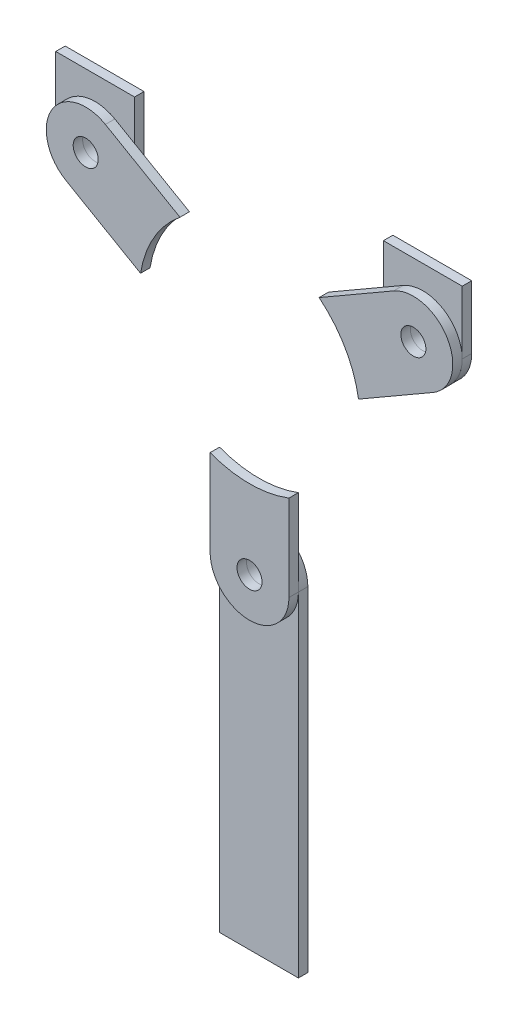
from build123d import *

# Parameters (mm, degrees)
SKETCH1_R             = 3.96875
BOSS_EXTRUDE1_DEPTH   = 3
BOSS_EXTRUDE1_2_DEPTH = 3
BOSS_EXTRUDE1_3_DEPTH = 3
SKETCH2_R             = 3.96875
BOSS_EXTRUDE2_DEPTH   = 3
BOSS_EXTRUDE2_2_DEPTH = 3
BOSS_EXTRUDE2_3_DEPTH = 3


with BuildPart() as part:
    # Sketch1 → Boss-Extrude1 (new body)
    with BuildSketch(Plane.XY):
        with BuildLine():
            ThreePointArc((-45.711524227, 40.825317547), (-62.786841774, 36.25), (-58.211524227, 19.174682453))
            Line((-58.211524227, 19.174682453), (-34.561879132, 5.520553491))
            ThreePointArc((-34.561879132, 5.520553491), (-30.310889132, 17.5), (-22.061879132, 27.171188586))
            Line((-22.061879132, 27.171188586), (-45.711524227, 40.825317547))
        make_face()
        with Locations((-51.961524227, 30)):
            Circle(SKETCH1_R, mode=Mode.SUBTRACT)
    extrude(amount=BOSS_EXTRUDE1_DEPTH)


with BuildPart() as body_2:
    # Sketch1 → Boss-Extrude1 2 (new body)
    with BuildSketch(Plane.XY):
        with BuildLine():
            ThreePointArc((58.211524227, 19.174682453), (62.786841774, 36.25), (45.711524227, 40.825317547))
            Line((45.711524227, 40.825317547), (22.061879132, 27.171188586))
            ThreePointArc((22.061879132, 27.171188586), (30.310889132, 17.5), (34.561879132, 5.520553491))
            Line((34.561879132, 5.520553491), (58.211524227, 19.174682453))
        make_face()
        with Locations((51.961524227, 30)):
            Circle(SKETCH1_R, mode=Mode.SUBTRACT)
    extrude(amount=BOSS_EXTRUDE1_2_DEPTH)


with BuildPart() as body_3:
    # Sketch1 → Boss-Extrude1 3 (new body)
    with BuildSketch(Plane.XY):
        with BuildLine():
            ThreePointArc((-12.5, -60), (0, -72.5), (12.5, -60))
            Line((12.5, -60), (12.5, -32.691742077))
            ThreePointArc((12.5, -32.691742077), (0, -35), (-12.5, -32.691742077))
            Line((-12.5, -32.691742077), (-12.5, -60))
        make_face()
        with Locations((0, -60)):
            Circle(SKETCH1_R, mode=Mode.SUBTRACT)
    extrude(amount=BOSS_EXTRUDE1_3_DEPTH)


with BuildPart() as body_4:
    # Sketch2 → Boss-Extrude2 (new body)
    with BuildSketch(Plane.XY):
        with BuildLine():
            Line((-64.461524227, 30), (-64.461524227, 50))
            Line((-64.461524227, 50), (-39.461524227, 50))
            Line((-39.461524227, 50), (-39.461524227, 30))
            ThreePointArc((-39.461524227, 30), (-51.961524227, 17.5), (-64.461524227, 30))
        make_face()
        with Locations((-51.961524227, 30)):
            Circle(SKETCH2_R, mode=Mode.SUBTRACT)
    extrude(amount=-BOSS_EXTRUDE2_DEPTH)


with BuildPart() as body_5:
    # Sketch2 → Boss-Extrude2 2 (new body)
    with BuildSketch(Plane.XY):
        with BuildLine():
            Line((64.461524227, 30), (64.461524227, 50))
            Line((64.461524227, 50), (39.461524227, 50))
            Line((39.461524227, 50), (39.461524227, 30))
            ThreePointArc((39.461524227, 30), (51.961524227, 17.5), (64.461524227, 30))
        make_face()
        with Locations((51.961524227, 30)):
            Circle(SKETCH2_R, mode=Mode.SUBTRACT)
    extrude(amount=-BOSS_EXTRUDE2_2_DEPTH)


with BuildPart() as body_6:
    # Sketch2 → Boss-Extrude2 3 (new body)
    with BuildSketch(Plane.XY):
        with BuildLine():
            Line((-12.5, -60), (-12.5, -166))
            Line((-12.5, -166), (12.5, -166))
            Line((12.5, -166), (12.5, -60))
            ThreePointArc((12.5, -60), (0, -47.5), (-12.5, -60))
        make_face()
        with Locations((0, -60)):
            Circle(SKETCH2_R, mode=Mode.SUBTRACT)
    extrude(amount=-BOSS_EXTRUDE2_3_DEPTH)


solid = Compound([part.part, body_2.part, body_3.part, body_4.part, body_5.part, body_6.part])
